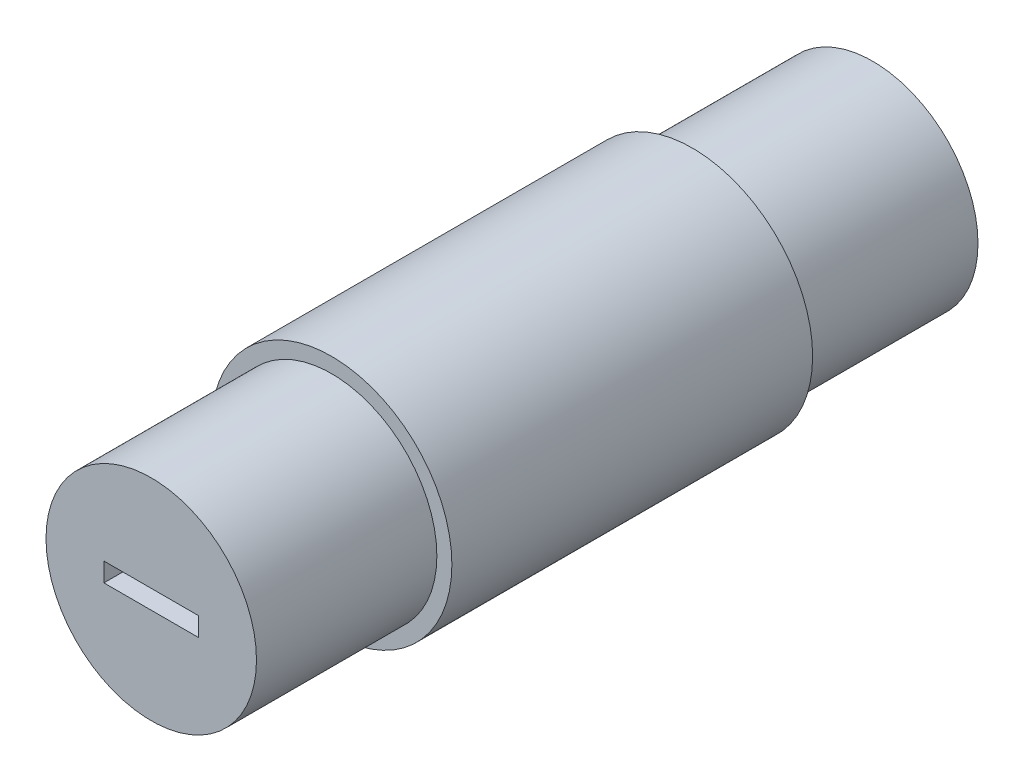
from build123d import *

# Parameters (mm, degrees)
SKETCH1_R                              = 12.7
BASE_EXTRUDE_DEPTH                     = 38.1
SKETCH2_R                              = 12.7
SKETCH2_R_2                            = 11.115
CUT_EXTRUDE1_DEPTH                     = 19.05
SKETCH3_W                              = 10
SKETCH3_H                              = 2
SLOT_FOR_FLAT_BLADE_SCREW_DRIVER_DEPTH = 6


with BuildPart() as part:
    # Sketch1 → Base-Extrude (new body, symmetric)
    with BuildSketch(Plane.XY):
        Circle(SKETCH1_R)
    extrude(amount=BASE_EXTRUDE_DEPTH, both=True)

    # Sketch2 → Cut-Extrude1 (cut)
    with BuildSketch(Plane.XY.offset(38.1)):
        Circle(SKETCH2_R)
        Circle(SKETCH2_R_2, mode=Mode.SUBTRACT)
    cut_extrude1 = extrude(amount=-CUT_EXTRUDE1_DEPTH, mode=Mode.SUBTRACT)

    # Mirror1: Cut-Extrude1 across plane
    add(cut_extrude1.mirror(Plane.XY), mode=Mode.SUBTRACT)

    # Sketch3 → Slot for Flat Blade Screw Driver (cut)
    with BuildSketch(Plane.XY.offset(38.1)):
        Rectangle(SKETCH3_W, SKETCH3_H)
    slot_for_flat_blade_screw_driver = extrude(amount=-SLOT_FOR_FLAT_BLADE_SCREW_DRIVER_DEPTH, mode=Mode.SUBTRACT)

    # Mirror2: Slot for Flat Blade Screw Driver across plane
    add(slot_for_flat_blade_screw_driver.mirror(Plane.XY), mode=Mode.SUBTRACT)


solid = part.part
